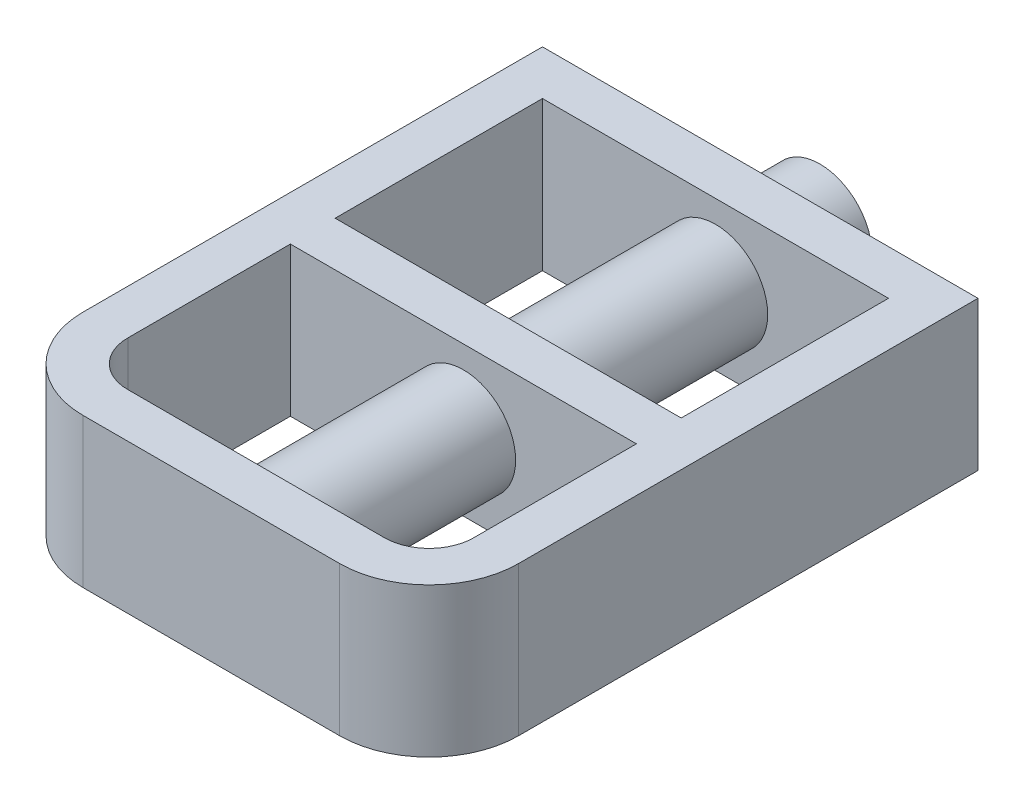
from build123d import *

# Parameters (mm, degrees)
CROQUIS1_W                   = 58
CROQUIS1_H                   = 34.75
SALIENTE_EXTRUIR1_DEPTH      = 12.5
CROQUIS2_R                   = 8.75
SALIENTE_EXTRUIR2_DEPTH      = 10
SALIENTE_EXTRUIR2_DEPTH_BACK = 84.5
CROQUIS3_R                   = 5
CORTAR_EXTRUIR1_DEPTH        = 94.5


with BuildPart() as part:
    # Croquis1 → Saliente-Extruir1 (new body, symmetric)
    with BuildSketch(Plane(origin=(0, 0, 0), x_dir=(1, 0, 0), z_dir=(0, 1, 0))):
        with BuildLine():
            Line((21.5, -46), (-21.5, -46))
            ThreePointArc((-21.5, -46), (-32.106601718, -41.606601718), (-36.5, -31))
            Line((-36.5, -31), (-36.5, 46))
            Line((-36.5, 46), (36.5, 46))
            Line((36.5, 46), (36.5, -31))
            ThreePointArc((36.5, -31), (32.106601718, -41.606601718), (21.5, -46))
        make_face()
        with BuildLine():
            Line((-29, -31), (-29, -3.75))
            Line((-29, -3.75), (29, -3.75))
            Line((29, -3.75), (29, -31))
            ThreePointArc((29, -31), (26.803300859, -36.303300859), (21.5, -38.5))
            Line((21.5, -38.5), (-21.5, -38.5))
            ThreePointArc((-21.5, -38.5), (-26.803300859, -36.303300859), (-29, -31))
        make_face(mode=Mode.SUBTRACT)
        with Locations((0, 21.125)):
            Rectangle(CROQUIS1_W, CROQUIS1_H, mode=Mode.SUBTRACT)
    extrude(amount=SALIENTE_EXTRUIR1_DEPTH, both=True)

    # Croquis2 → Saliente-Extruir2 (add, two sides)
    with BuildSketch(Plane(origin=(0, 0, -46), x_dir=(-1, 0, 0), z_dir=(0, 0, -1))) as saliente_extruir2_sk:
        Circle(CROQUIS2_R)
    extrude(amount=SALIENTE_EXTRUIR2_DEPTH)
    extrude(saliente_extruir2_sk.sketch, amount=-SALIENTE_EXTRUIR2_DEPTH_BACK)

    # Croquis3 → Cortar-Extruir1 (cut)
    with BuildSketch(Plane(origin=(0, 0, -56), x_dir=(-1, 0, 0), z_dir=(0, 0, -1))):
        Circle(CROQUIS3_R)
    extrude(amount=-CORTAR_EXTRUIR1_DEPTH, mode=Mode.SUBTRACT)


solid = part.part
